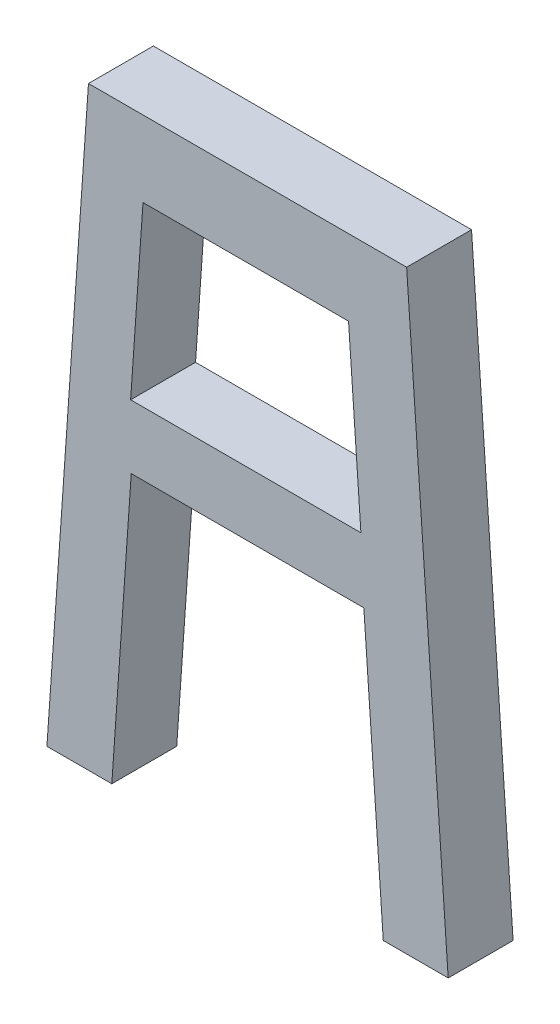
from build123d import *

# Parameters (mm, degrees)
BOSS_EXTRUDE1_DEPTH = 12.7
CUT_EXTRUDE3_DEPTH  = 12.7


with BuildPart() as part:
    # Sketch1 → Boss-Extrude1 (new body)
    with BuildSketch(Plane.XY):
        Polygon((-39.258980401, 44.296675518), (-31.128110258, 160.684002306), (31.128110258, 160.684002306), (39.258980401, 44.296675518), (26.558980401, 44.296675518), (22.753914358, 98.763350938), (-22.753914358, 98.763350938), (-26.558980401, 44.296675518), align=None)
    extrude(amount=BOSS_EXTRUDE1_DEPTH)

    # Sketch5 → Cut-Extrude3 (cut)
    with BuildSketch(Plane.XY.offset(12.7)):
        Polygon((-20.458686011, 145.848553897), (-22.878932211, 111.204539111), (22.182375422, 111.204539111), (19.762129221, 145.848553897), align=None)
    extrude(amount=-CUT_EXTRUDE3_DEPTH, mode=Mode.SUBTRACT)


solid = part.part
